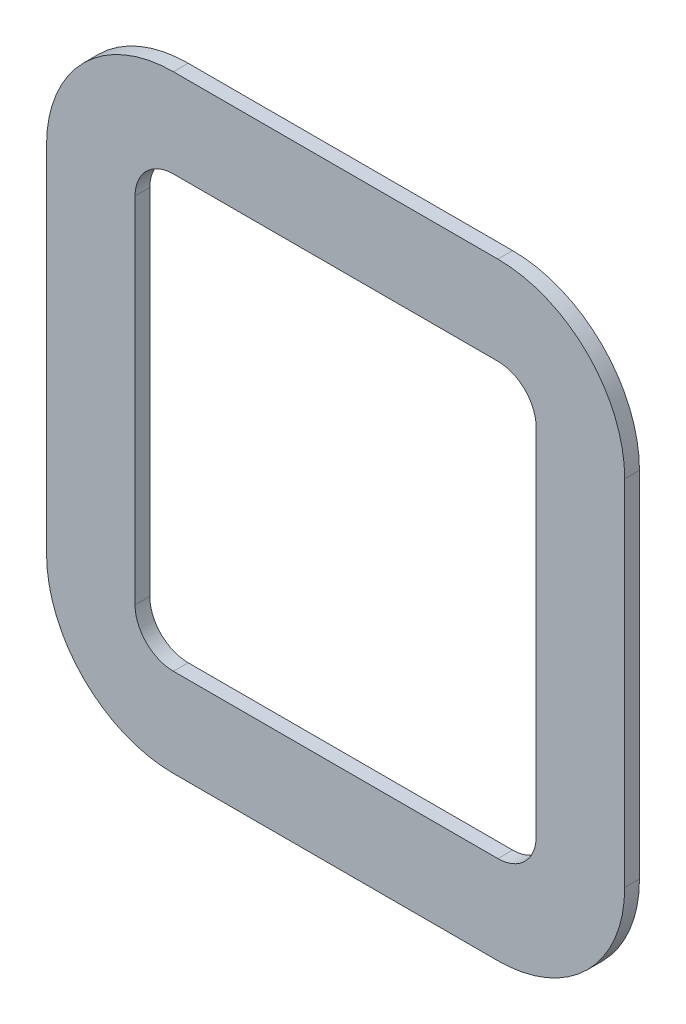
from build123d import *

# Parameters (mm, degrees)
BOSS_EXTRUDE1_DEPTH = 0.5


with BuildPart() as part:
    # Sketch1 → Boss-Extrude1 (new body)
    with BuildSketch(Plane.XY):
        with BuildLine():
            Line((5.499999476, 10.300000481), (-5.500000524, 10.300000481))
            ThreePointArc((-5.500000524, 10.300000481), (-8.540559684, 9.04055964), (-9.800000524, 6.000000481))
            Line((-9.800000524, 6.000000481), (-9.800000524, -6.000000481))
            ThreePointArc((-9.800000524, -6.000000481), (-8.540559684, -9.04055964), (-5.500000524, -10.300000481))
            Line((-5.500000524, -10.300000481), (5.499999476, -10.300000481))
            ThreePointArc((5.499999476, -10.300000481), (8.540558635, -9.04055964), (9.799999476, -6.000000481))
            Line((9.799999476, -6.000000481), (9.799999476, 6.000000481))
            ThreePointArc((9.799999476, 6.000000481), (8.540558635, 9.04055964), (5.499999476, 10.300000481))
        make_face()
        with BuildLine():
            Line((5.499999476, 7.300000481), (-5.500000524, 7.300000481))
            ThreePointArc((-5.500000524, 7.300000481), (-6.41923934, 6.919239296), (-6.800000524, 6.000000481))
            Line((-6.800000524, 6.000000481), (-6.800000524, -6.000000481))
            ThreePointArc((-6.800000524, -6.000000481), (-6.41923934, -6.919239296), (-5.500000524, -7.300000481))
            Line((-5.500000524, -7.300000481), (5.499999476, -7.300000481))
            ThreePointArc((5.499999476, -7.300000481), (6.419238291, -6.919239296), (6.799999476, -6.000000481))
            Line((6.799999476, -6.000000481), (6.799999476, 6.000000481))
            ThreePointArc((6.799999476, 6.000000481), (6.419238291, 6.919239296), (5.499999476, 7.300000481))
        make_face(mode=Mode.SUBTRACT)
    extrude(amount=-BOSS_EXTRUDE1_DEPTH)


solid = part.part
